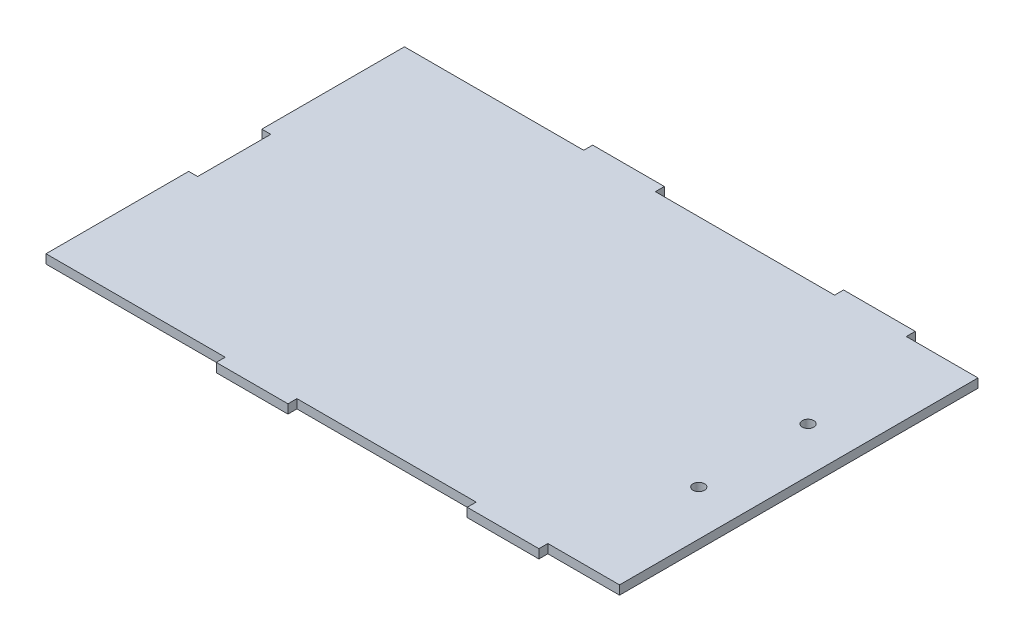
from build123d import *

# Parameters (mm, degrees)
SKETCH1_W           = 203.2
SKETCH1_H           = 127
SKETCH1_R           = 2.032
BOSS_EXTRUDE1_DEPTH = 3.175
SKETCH5_W           = 25.4
SKETCH5_H           = 3.175
BOSS_EXTRUDE2_DEPTH = 3.175
SKETCH6_W           = 25.4
SKETCH6_H           = 3.175
BOSS_EXTRUDE3_DEPTH = 3.175
SKETCH7_W           = 25.908
SKETCH7_H           = 3.175
CUT_EXTRUDE1_DEPTH  = 3.175


with BuildPart() as part:
    # Sketch1 → Boss-Extrude1 (new body)
    with BuildSketch(Plane(origin=(0, 0, 0), x_dir=(1, 0, 0), z_dir=(0, 1, 0))):
        with Locations((42.361845493, 11.49358269)):
            Rectangle(SKETCH1_W, SKETCH1_H)
        with Locations((127.959845493, -7.93741731)):
            Circle(SKETCH1_R, mode=Mode.SUBTRACT)
        with Locations((127.959845493, 30.79758269)):
            Circle(SKETCH1_R, mode=Mode.SUBTRACT)
    extrude(amount=BOSS_EXTRUDE1_DEPTH)

    # Sketch5 → Boss-Extrude2 (add)
    with BuildSketch(Plane.XY.offset(52.00641731)):
        with Locations((16.961845493, 1.5875)):
            Rectangle(SKETCH5_W, SKETCH5_H)
        with Locations((105.861845493, 1.5875)):
            Rectangle(SKETCH5_W, SKETCH5_H)
    extrude(amount=BOSS_EXTRUDE2_DEPTH)

    # Sketch6 → Boss-Extrude3 (add)
    with BuildSketch(Plane(origin=(0, 0, -74.99358269), x_dir=(-1, 0, 0), z_dir=(0, 0, -1))):
        with Locations((-105.861845493, 1.5875)):
            Rectangle(SKETCH6_W, SKETCH6_H)
        with Locations((-16.961845493, 1.5875)):
            Rectangle(SKETCH6_W, SKETCH6_H)
    extrude(amount=BOSS_EXTRUDE3_DEPTH)

    # Sketch7 → Cut-Extrude1 (cut)
    with BuildSketch(Plane.ZY.offset(59.238154507)):
        with Locations((-11.49358269, 1.5875)):
            Rectangle(SKETCH7_W, SKETCH7_H)
    extrude(amount=-CUT_EXTRUDE1_DEPTH, mode=Mode.SUBTRACT)


solid = part.part
